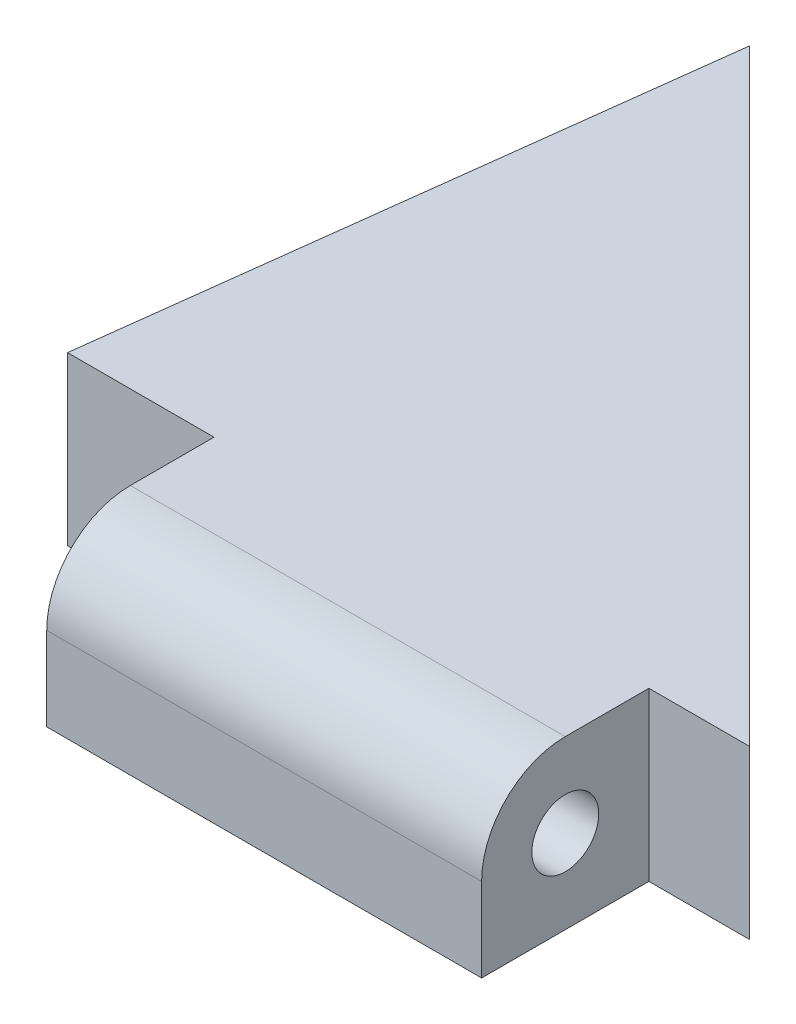
from build123d import *

# Parameters (mm, degrees)
BOSS_EXTRUDE1_DEPTH = 6.35
BOSS_EXTRUDE2_START = -3.81
SKETCH2_R           = 3.175
SKETCH2_R_2         = 1.27
BOSS_EXTRUDE2_DEPTH = 16.51


with BuildPart() as part:
    # Sketch1 → Boss-Extrude1 (new body)
    with BuildSketch(Plane(origin=(0, 0, 0), x_dir=(1, 0, 0), z_dir=(0, 1, 0))):
        Polygon((-25.881030621, 0), (-23.020766125, 23.020766125), (0, 0), align=None)
    extrude(amount=BOSS_EXTRUDE1_DEPTH)

    # Sketch2 → Boss-Extrude2 (add)
    with BuildSketch(Plane(origin=(0, 0, 0), x_dir=(0, 0, -1), z_dir=(1, 0, 0)).offset(BOSS_EXTRUDE2_START)):
        with Locations((-3.175, 3.175)):
            Circle(SKETCH2_R)
        with Locations((-3.175, 3.175)):
            Circle(SKETCH2_R_2, mode=Mode.SUBTRACT)
        with BuildLine():
            ThreePointArc((-3.174999994, 6.35), (-0.929935968, 5.420064028), (0, 3.175))
            Line((0, 3.175), (0, 6.35))
            Line((0, 6.35), (-3.174999994, 6.35))
        make_face()
        with BuildLine():
            ThreePointArc((0, 3.175), (-0.92993597, 0.92993597), (-3.175, 0))
            Line((-3.175, 0), (0, 0))
            Line((0, 0), (0, 3.175))
        make_face()
        with BuildLine():
            Line((-6.35, 3.175), (-6.35, 0))
            Line((-6.35, 0), (-3.175, 0))
            ThreePointArc((-3.175, 0), (-5.42006403, 0.92993597), (-6.35, 3.175))
        make_face()
    extrude(amount=-BOSS_EXTRUDE2_DEPTH)


solid = part.part
